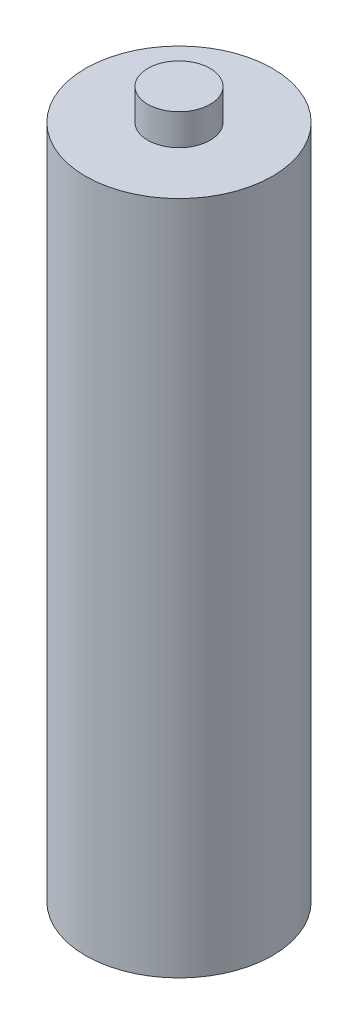
from build123d import *

# Parameters (mm, degrees)
SKETCH1_R           = 9
BOSS_EXTRUDE1_DEPTH = 65
SKETCH2_R           = 3
BOSS_EXTRUDE2_DEPTH = 3


with BuildPart() as part:
    # Sketch1 → Boss-Extrude1 (new body)
    with BuildSketch(Plane(origin=(0, 0, 0), x_dir=(1, 0, 0), z_dir=(0, 1, 0))):
        Circle(SKETCH1_R)
    extrude(amount=BOSS_EXTRUDE1_DEPTH)

    # Sketch2 → Boss-Extrude2 (add)
    with BuildSketch(Plane(origin=(0, 65, 0), x_dir=(1, 0, 0), z_dir=(0, 1, 0))):
        Circle(SKETCH2_R)
    extrude(amount=BOSS_EXTRUDE2_DEPTH)


solid = part.part
